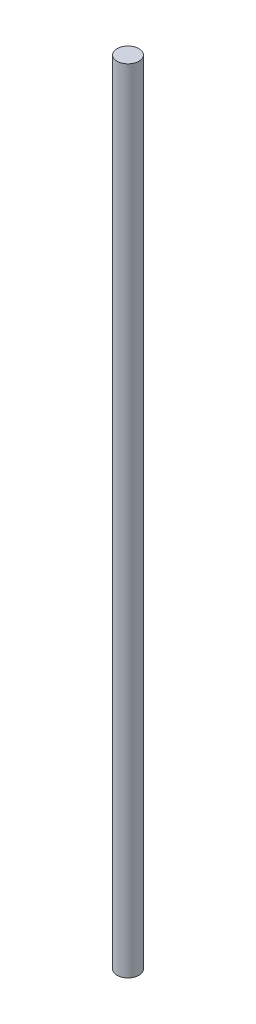
from build123d import *

# Parameters (mm, degrees)
SKETCH1_R           = 3.175
BOSS_EXTRUDE1_DEPTH = 230


with BuildPart() as part:
    # Sketch1 → Boss-Extrude1 (new body)
    with BuildSketch(Plane(origin=(0, 0, 0), x_dir=(1, 0, 0), z_dir=(0, 1, 0))):
        Circle(SKETCH1_R)
    extrude(amount=BOSS_EXTRUDE1_DEPTH)


solid = part.part
